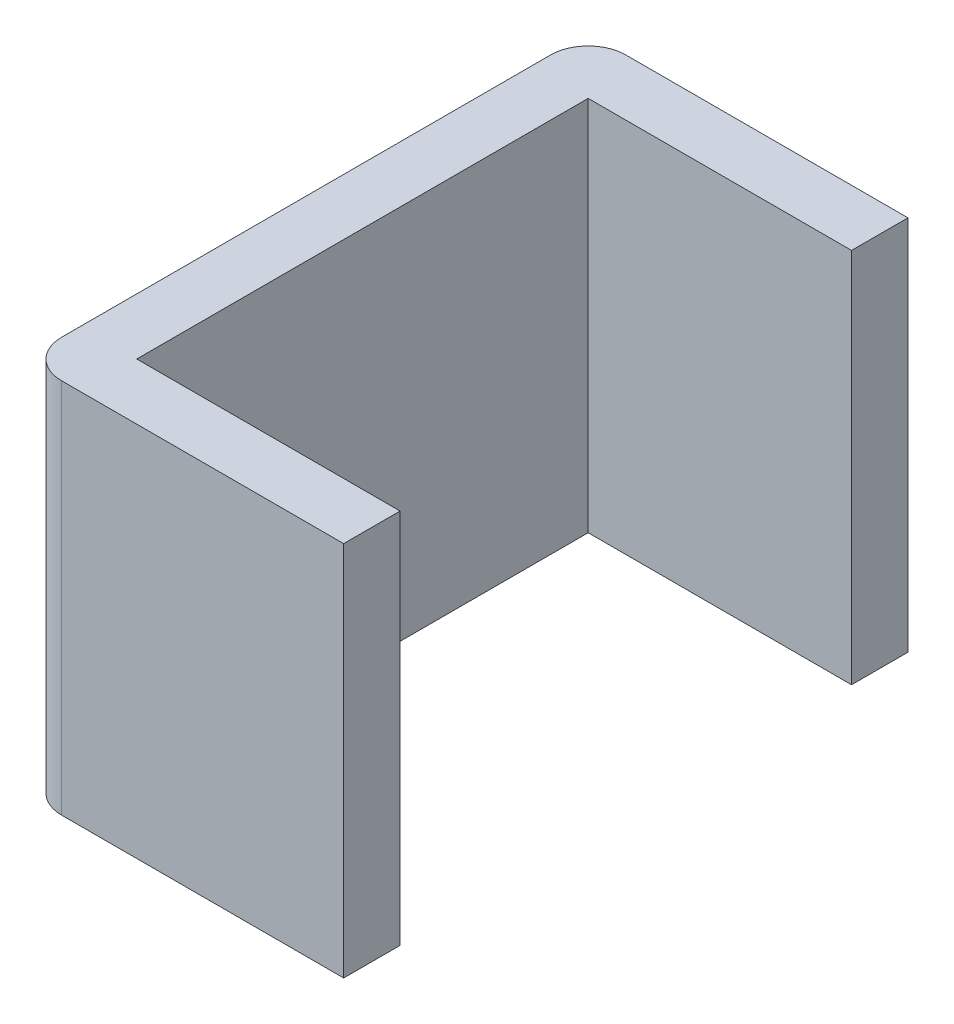
from build123d import *

# Parameters (mm, degrees)
BOSS_EXTRUDE1_DEPTH = 20
FILLET1_R           = 2


with BuildPart() as part:
    # Sketch1 → Boss-Extrude1 (new body)
    with BuildSketch(Plane(origin=(0, 0, 0), x_dir=(1, 0, 0), z_dir=(0, 1, 0))):
        Polygon((0, 0), (-17, 0), (-17, 30), (0, 30), (0, 27), (-14, 27), (-14, 3), (0, 3), align=None)
    extrude(amount=BOSS_EXTRUDE1_DEPTH)

    # Fillet1
    fillet1_edges = [part.edges().sort_by_distance(p)[0] for p in [
        (-17, 10, 0),
        (-17, 10, -30),
    ]]
    fillet(fillet1_edges, radius=FILLET1_R)


solid = part.part
